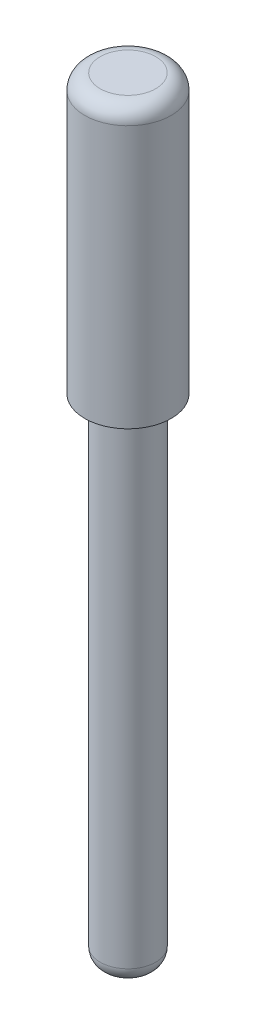
from build123d import *

# Parameters (mm, degrees)
SKETCH_1_R      = 1.4
EXTRUDE_1_DEPTH = 25
SKETCH_2_W      = 0.5
SKETCH_2_H      = 16
FILLET_1_R      = 0.5


with BuildPart() as part:
    # 草图1 → 凸台-拉伸1 (new body)
    with BuildSketch(Plane(origin=(0, 0, 0), x_dir=(1, 0, 0), z_dir=(0, 1, 0))):
        Circle(SKETCH_1_R)
    extrude(amount=EXTRUDE_1_DEPTH)

    # 草图2 → 切除-旋转1 (revolve, cut)
    with BuildSketch(Plane(origin=(0, 0, 0), x_dir=(0, 0, -1), z_dir=(1, 0, 0))):
        with Locations((1.15, 8)):
            Rectangle(SKETCH_2_W, SKETCH_2_H)
    revolve(axis=Axis((0, 0, 0), (0, -1, 0)), mode=Mode.SUBTRACT)

    # 圆角1
    fillet_1_edges = [part.edges().sort_by_distance(p)[0] for p in [
        (-1.4, 25, 0),
        (0, 0, 0.9),
    ]]
    fillet(fillet_1_edges, radius=FILLET_1_R)


solid = part.part
